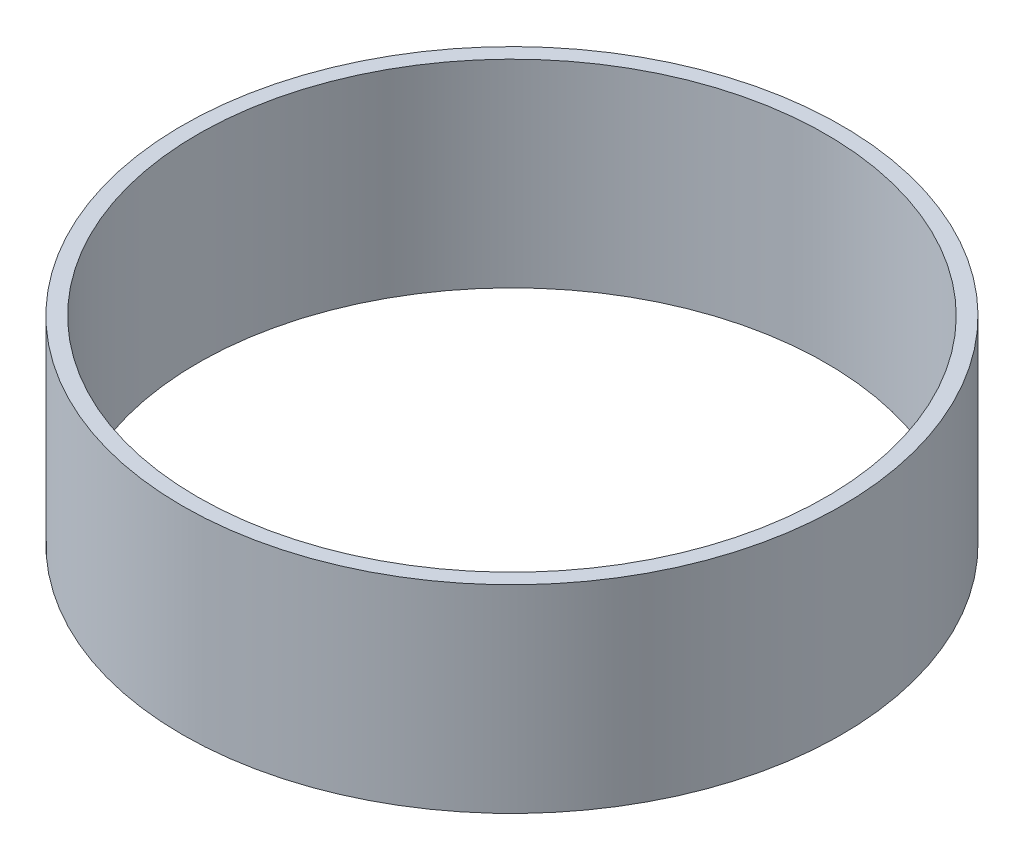
from build123d import *

# Parameters (mm, degrees)
SKETCH1_R    = 38.1
SKETCH1_R_2  = 36.322
WINDOW_DEPTH = 22.8981


with BuildPart() as part:
    # Sketch1 → window (new body)
    with BuildSketch(Plane(origin=(0, 0, 0), x_dir=(1, 0, 0), z_dir=(0, 1, 0))):
        Circle(SKETCH1_R)
        Circle(SKETCH1_R_2, mode=Mode.SUBTRACT)
    extrude(amount=WINDOW_DEPTH)


solid = part.part
